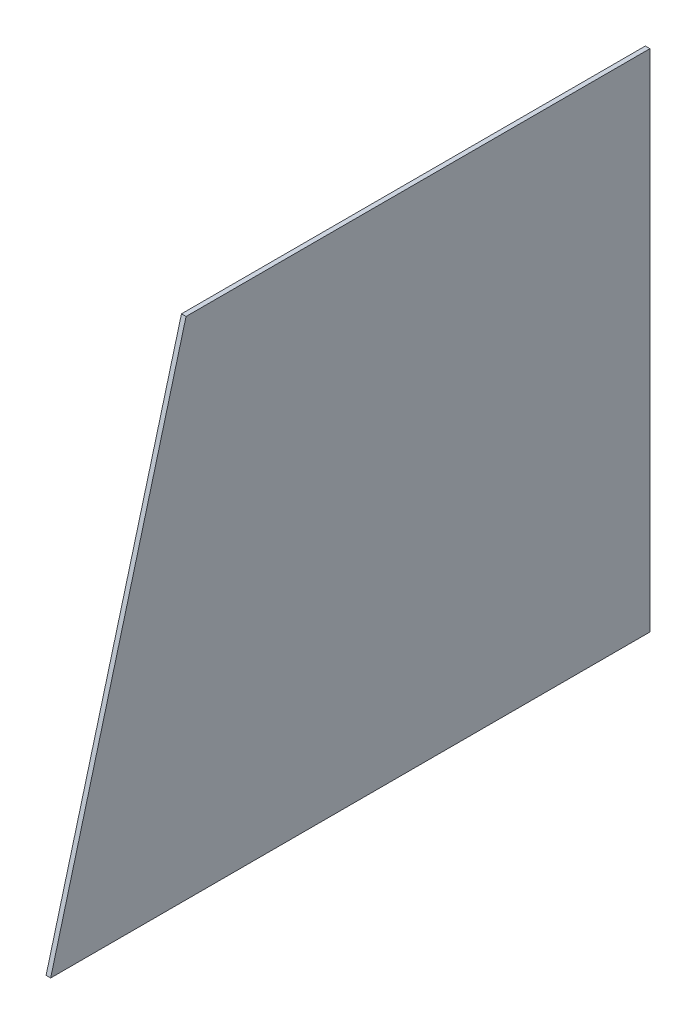
from build123d import *

# Parameters (mm, degrees)
BOSS_EXTRUDE1_DEPTH = 3


with BuildPart() as part:
    # Sketch1 → Boss-Extrude1 (new body)
    with BuildSketch(Plane(origin=(0, 0, 0), x_dir=(0, 0, -1), z_dir=(1, 0, 0))):
        Polygon((-196.098076211, -165.327172392), (-107.499511553, 165.327172392), (193.098076211, 165.327172392), (196.098076211, 165.327172392), (196.098076211, -165.327172392), (193.098076211, -165.327172392), align=None)
    extrude(amount=BOSS_EXTRUDE1_DEPTH)


solid = part.part
